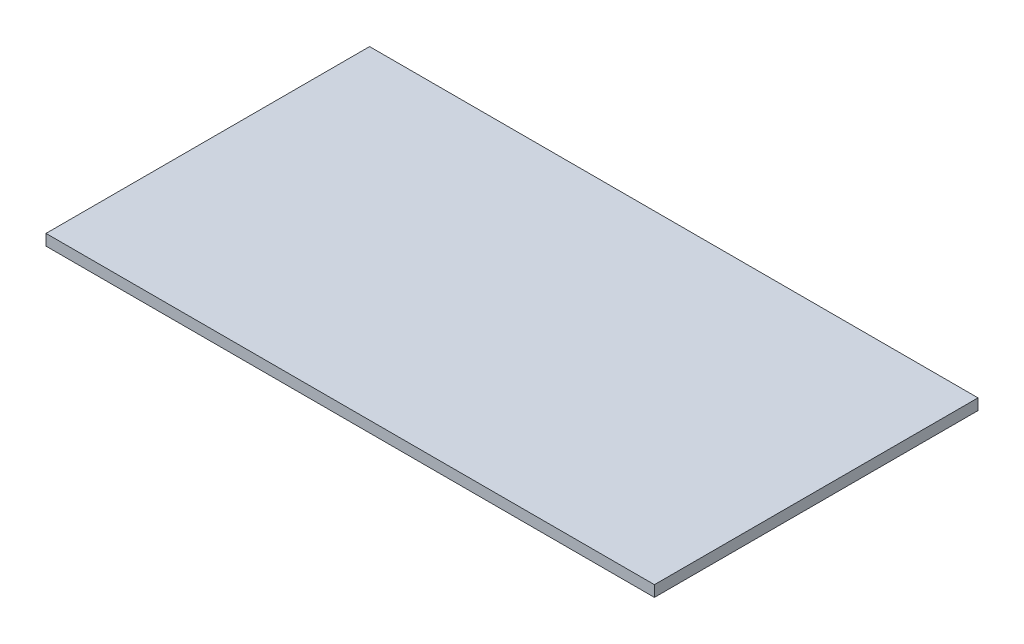
from build123d import *

# Parameters (mm, degrees)
SKETCH1_W           = 220
SKETCH1_H           = 117
BOSS_EXTRUDE1_DEPTH = 4


with BuildPart() as part:
    # Sketch1 → Boss-Extrude1 (new body)
    with BuildSketch(Plane(origin=(0, 0, 0), x_dir=(1, 0, 0), z_dir=(0, 1, 0))):
        Rectangle(SKETCH1_W, SKETCH1_H)
    extrude(amount=BOSS_EXTRUDE1_DEPTH)


solid = part.part
